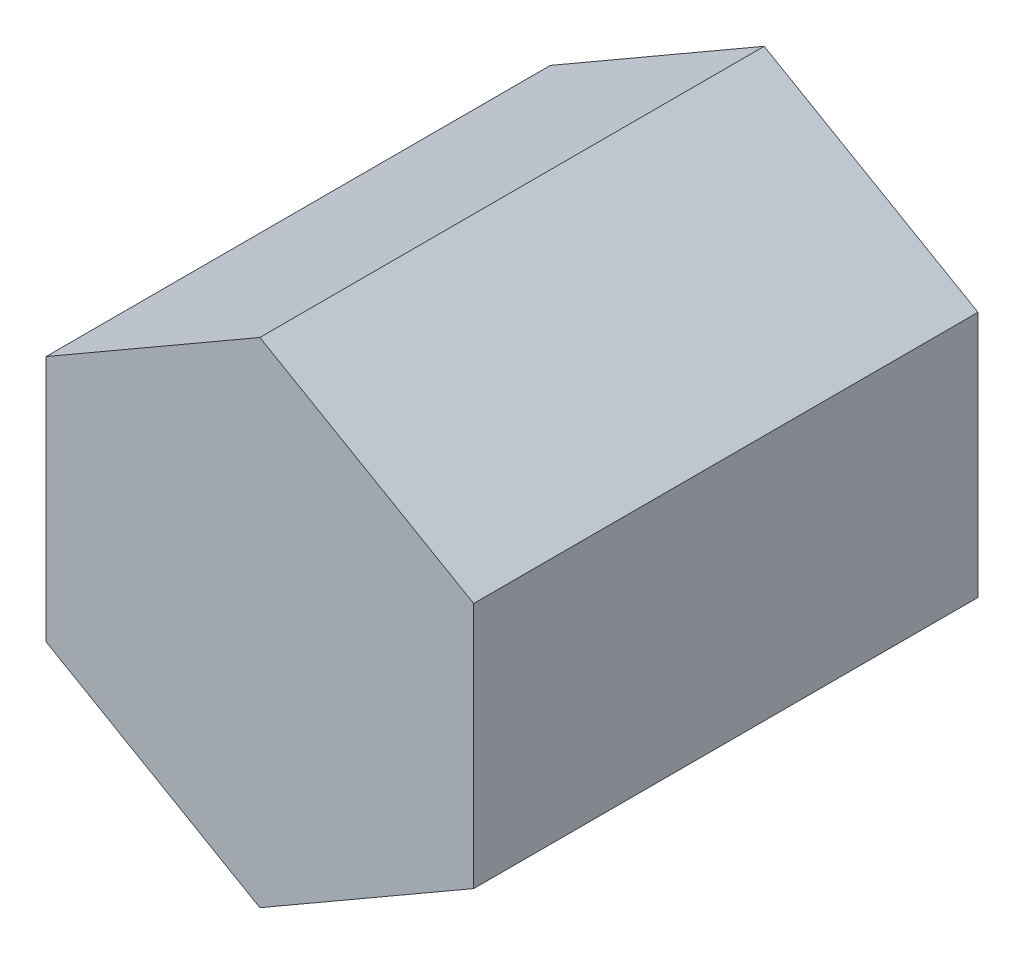
from build123d import *

# Parameters (mm, degrees)
BOSS_EXTRUDE1_DEPTH = 25


with BuildPart() as part:
    # Sketch1 → Boss-Extrude1 (new body, symmetric)
    with BuildSketch(Plane.XY):
        Polygon((0, 24.479651414), (-21.2, 12.239825707), (-21.2, -12.239825707), (0, -24.479651414), (21.2, -12.239825707), (21.2, 12.239825707), align=None)
    extrude(amount=BOSS_EXTRUDE1_DEPTH, both=True)


solid = part.part
